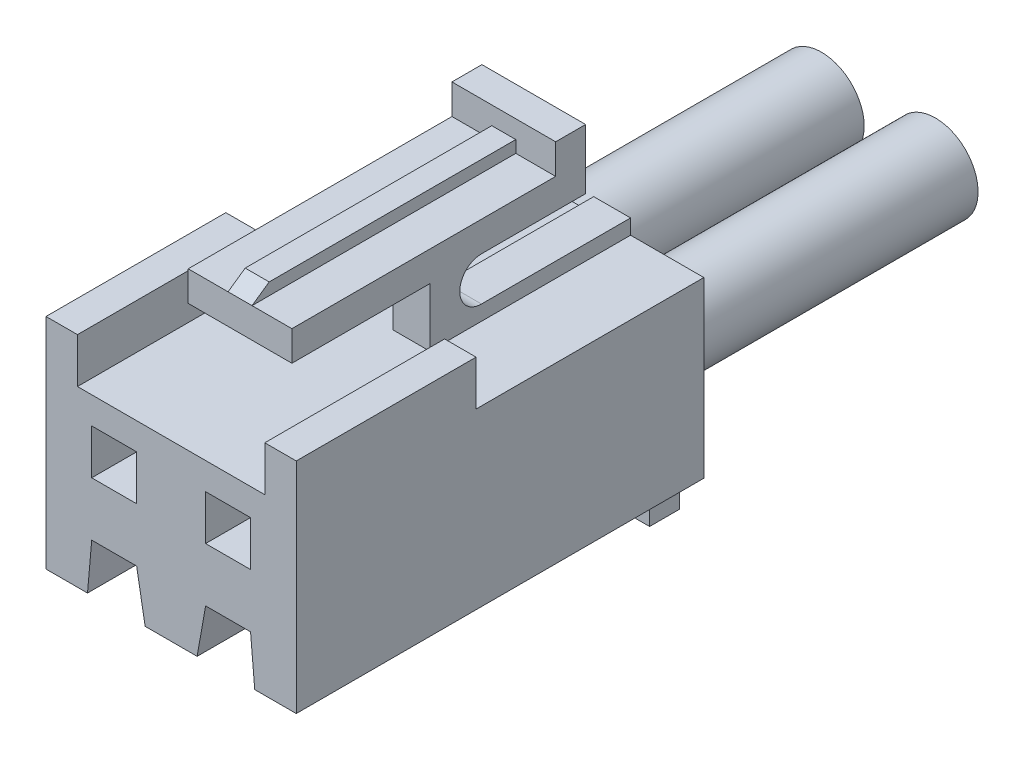
from build123d import *

# Parameters (mm, degrees)
ESQUISSE1_W               = 1.5
ESQUISSE1_H               = 1.5
BOSS_EXTRU_1_DEPTH        = 13.6
BOSS_EXTRU_2_DEPTH        = 1.73
BOSS_EXTRU_3_DEPTH        = 0.4
BOSS_EXTRU_4_DEPTH        = 0.4
ESQUISSE5_W               = 1
ESQUISSE5_H               = 1.95
ENL_V_MAT_EXTRU_1_DEPTH   = 6.7
ESQUISSE6_W               = 6.73
ESQUISSE6_H               = 1
BOSS_EXTRU_5_DEPTH        = 1.3
ESQUISSE8_W               = 7.6
ESQUISSE8_H               = 1.5
ENL_V_MAT_EXTRU_3_DEPTH   = 1.1
ENL_V_MAT_EXTRU_2_DEPTH   = 11.6
ENL_V_MAT_EXTRU_4_DEPTH   = 5.8
ESQUISSE11_R              = 1.425
BOSS_EXTRU_6_DEPTH        = 10
BOSS_EXTRU_6_DEPTH_BACK   = 3
BOSS_EXTRU_6_2_DEPTH      = 10
BOSS_EXTRU_6_2_DEPTH_BACK = 3


with BuildPart() as part:
    # Esquisse1 → Boss.-Extru.1 (new body)
    with BuildSketch(Plane.XY):
        Polygon((-4.175, 3.15), (-3.125, 3.15), (-3.125, 1.65), (3.125, 1.65), (3.125, 3.15), (4.175, 3.15), (4.175, -4.15), (-4.175, -4.15), align=None)
        with Locations((-1.9, 0)):
            Rectangle(ESQUISSE1_W, ESQUISSE1_H, mode=Mode.SUBTRACT)
        with Locations((1.9, 0)):
            Rectangle(ESQUISSE1_W, ESQUISSE1_H, mode=Mode.SUBTRACT)
    extrude(amount=-BOSS_EXTRU_1_DEPTH)

    # Esquisse2 → Boss.-Extru.2 (add, symmetric)
    with BuildSketch(Plane(origin=(0, 0, 0), x_dir=(0, 0, -1), z_dir=(1, 0, 0))):
        with BuildLine():
            Line((2.3, 4.6), (11.1, 4.6))
            Line((11.1, 4.6), (11.1, 5.6))
            Line((11.1, 5.6), (12.1, 5.6))
            Line((12.1, 5.6), (12.1, 3.6))
            Line((12.1, 3.6), (8.625, 3.6))
            ThreePointArc((8.625, 3.6), (7.9, 2.875), (8.625, 2.15))
            Line((8.625, 2.15), (13.6, 2.15))
            Line((13.6, 2.15), (13.6, 1.65))
            Line((13.6, 1.65), (6.9, 1.65))
            Line((6.9, 1.65), (6.9, 3.6))
            Line((6.9, 3.6), (2.3, 3.6))
            Line((2.3, 3.6), (2.3, 4.6))
        make_face()
    extrude(amount=BOSS_EXTRU_2_DEPTH, both=True)

    # Esquisse3 → Boss.-Extru.3 (add, symmetric)
    with BuildSketch(Plane(origin=(0, 0, 0), x_dir=(0, 0, -1), z_dir=(1, 0, 0))):
        Polygon((2.3, 4.6), (2.871259203, 5), (11.1, 5), (11.1, 4.6), align=None)
    extrude(amount=BOSS_EXTRU_3_DEPTH, both=True)

    # Esquisse4 → Boss.-Extru.4 (add, symmetric)
    with BuildSketch(Plane(origin=(0, 0, 0), x_dir=(0, 0, -1), z_dir=(1, 0, 0))):
        Polygon((4.3, 3.6), (4.3, 2.8), (2.3, 3.6), align=None)
    extrude(amount=BOSS_EXTRU_4_DEPTH, both=True)

    # Esquisse5 → Enlèv. mat.-Extru.1 (cut)
    with BuildSketch(Plane(origin=(0, 0, -13.6), x_dir=(-1, 0, 0), z_dir=(0, 0, -1))):
        with Locations((0, 2.625)):
            Rectangle(ESQUISSE5_W, ESQUISSE5_H)
    extrude(amount=-ENL_V_MAT_EXTRU_1_DEPTH, mode=Mode.SUBTRACT)

    # Esquisse6 → Boss.-Extru.5 (add)
    with BuildSketch(Plane.XZ.offset(4.15)):
        with Locations((0, -13.1)):
            Rectangle(ESQUISSE6_W, ESQUISSE6_H)
    extrude(amount=BOSS_EXTRU_5_DEPTH)

    # Esquisse8 → Enlèv. mat.-Extru.3 (cut)
    with BuildSketch(Plane(origin=(4.175, 0, 0), x_dir=(0, 0, -1), z_dir=(1, 0, 0))):
        with Locations((9.8, 2.4)):
            Rectangle(ESQUISSE8_W, ESQUISSE8_H)
    enl_v_mat_extru_3 = extrude(amount=-ENL_V_MAT_EXTRU_3_DEPTH, mode=Mode.SUBTRACT)

    # Symétrie1: Enlèv. mat.-Extru.3 across plane
    add(enl_v_mat_extru_3.mirror(Plane(origin=(0, 0, 0), x_dir=(0, 0, 1), z_dir=(1, 0, 0))), mode=Mode.SUBTRACT)

    # Esquisse7 → Enlèv. mat.-Extru.2 (cut)
    with BuildSketch(Plane(origin=(0, 0, -13.6), x_dir=(-1, 0, 0), z_dir=(0, 0, -1))):
        Polygon((-3.675, 1.15), (-0.25, 1.15), (-0.25, -3.15), (-1.1, -3.15), (-1.1, -3.65), (-2.7, -3.65), (-2.7, -3.15), (-3.675, -3.15), align=None)
        Polygon((3.675, 1.15), (3.675, -3.15), (2.7, -3.15), (2.7, -3.65), (1.1, -3.65), (1.1, -3.15), (0.25, -3.15), (0.25, 1.15), align=None)
    extrude(amount=-ENL_V_MAT_EXTRU_2_DEPTH, mode=Mode.SUBTRACT)

    # Esquisse10 → Enlèv. mat.-Extru.4 (cut)
    with BuildSketch(Plane.XY):
        Polygon((2.789981862, -4.15), (2.65, -2.55), (1.15, -2.55), (0.867876831, -4.15), align=None)
        Polygon((-0.867876831, -4.15), (-2.789981862, -4.15), (-2.65, -2.55), (-1.15, -2.55), align=None)
    extrude(amount=-ENL_V_MAT_EXTRU_4_DEPTH, mode=Mode.SUBTRACT)


with BuildPart() as body_2:
    # Esquisse11 → Boss.-Extru.6 (new body, two sides)
    with BuildSketch(Plane(origin=(0, 0, -13.6), x_dir=(-1, 0, 0), z_dir=(0, 0, -1))) as boss_extru_6_sk:
        with Locations((-1.9, -1.3)):
            Circle(ESQUISSE11_R)
    extrude(amount=BOSS_EXTRU_6_DEPTH)
    extrude(boss_extru_6_sk.sketch, amount=-BOSS_EXTRU_6_DEPTH_BACK)


with BuildPart() as body_3:
    # Esquisse11 → Boss.-Extru.6 2 (new body, two sides)
    with BuildSketch(Plane(origin=(0, 0, -13.6), x_dir=(-1, 0, 0), z_dir=(0, 0, -1))) as boss_extru_6_2_sk:
        with Locations((1.9, -1.3)):
            Circle(ESQUISSE11_R)
    extrude(amount=BOSS_EXTRU_6_2_DEPTH)
    extrude(boss_extru_6_2_sk.sketch, amount=-BOSS_EXTRU_6_2_DEPTH_BACK)


solid = Compound([part.part, body_2.part, body_3.part])
